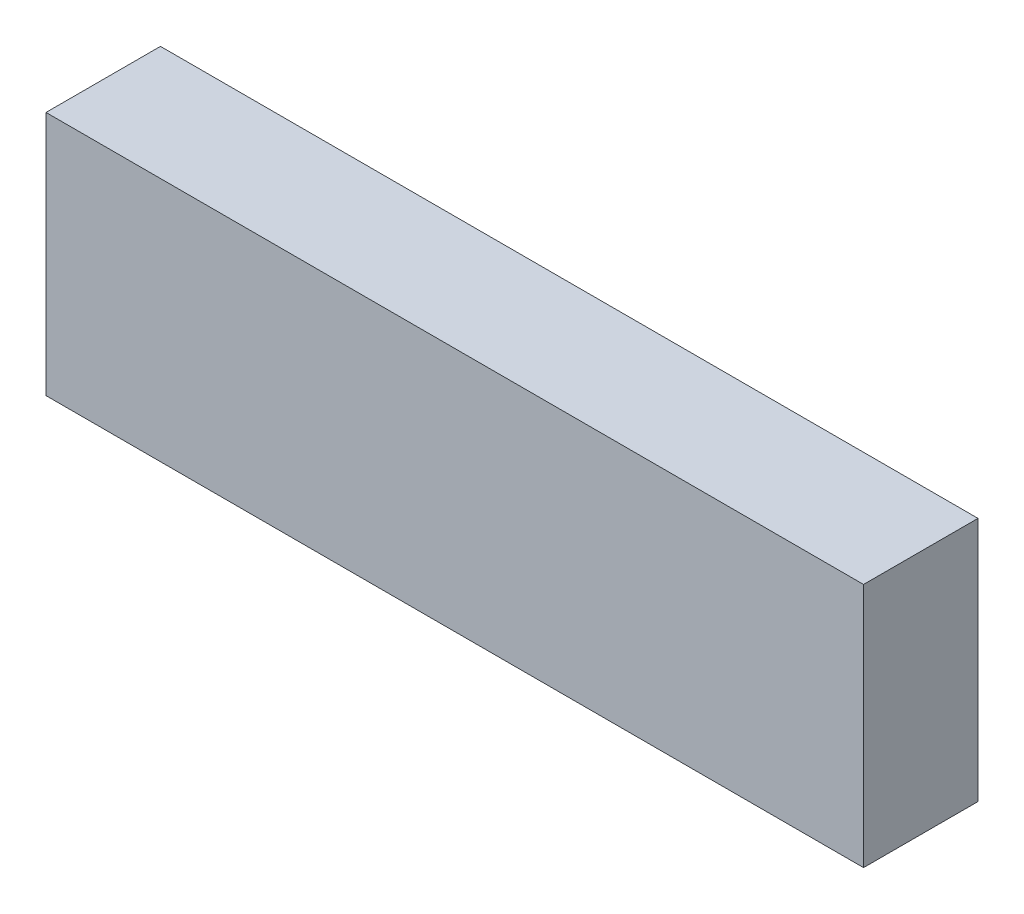
from build123d import *

# Parameters (mm, degrees)
SKETCH1_W           = 127
SKETCH1_H           = 38.1
BOSS_EXTRUDE1_DEPTH = 17.78


with BuildPart() as part:
    # Sketch1 → Boss-Extrude1 (new body)
    with BuildSketch(Plane.XY):
        with Locations((-1.852559201, 3.336393476)):
            Rectangle(SKETCH1_W, SKETCH1_H)
    extrude(amount=BOSS_EXTRUDE1_DEPTH)


solid = part.part
